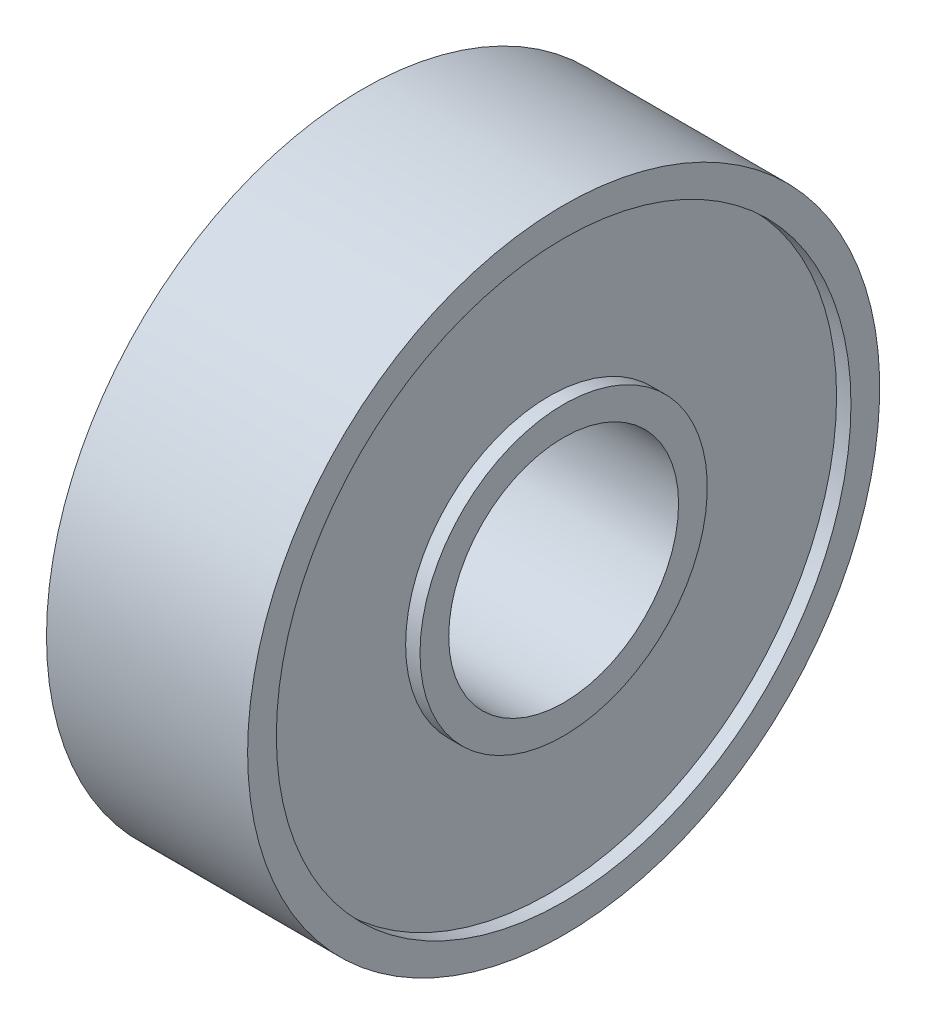
from build123d import *


with BuildPart() as part:
    # Sketch1 → Revolve1 (revolve)
    with BuildSketch(Plane.XY):
        Polygon((-3.5, 11), (3.5, 11), (3.5, 10), (3, 10), (3, 5), (3.5, 5), (3.5, 4), (-3.5, 4), (-3.5, 5), (-3, 5), (-3, 10), (-3.5, 10), align=None)
    revolve(axis=Axis((-3.354431458, 0, 0), (1, 0, 0)))


solid = part.part
